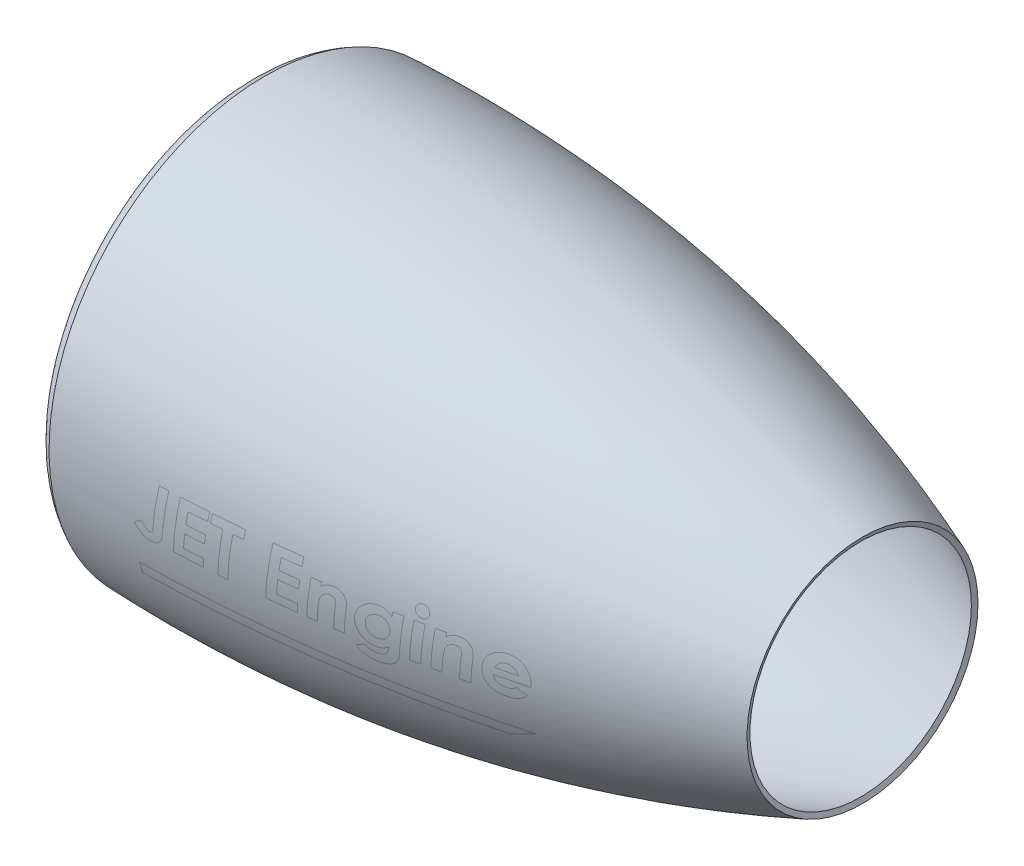
from build123d import *

# Parameters (mm, degrees)
THICKEN1_T1 = 5


with BuildPart() as body_1:
    # Surface-Revolve1: a surface, the sketch's curves turned about an axis
    with BuildLine(Plane.XY, mode=Mode.PRIVATE) as surface_revolve1_1_path:
        Line((59.462305436, 190), (34.462305436, 190))
        Line((34.462305436, 190), (25, 180))
        Line((25, 180), (0, 180))
        add(Edge.make_bspline(
            [(0, 180), (-6.975197262, 182.695130732), (-10.929497594, 190.356670201), (-11.003591647, 199.848313969), (0, 205.481359601)],
            knots=[0, 0, 0, 0, 0.423982122, 1, 1, 1, 1], degree=3))
        add(Edge.make_bspline(
            [(0, 205.481359601), (299.703455173, 217.025834014), (580, 108)],
            knots=[0, 0, 0, 1, 1, 1], degree=2))
    surface_revolve1_1 = Shell.revolve(surface_revolve1_1_path.wire(), 360, Axis((0, 0, 0), (1, 0, 0)))
    add(Solid.thicken(surface_revolve1_1, THICKEN1_T1))


solid = body_1.part
